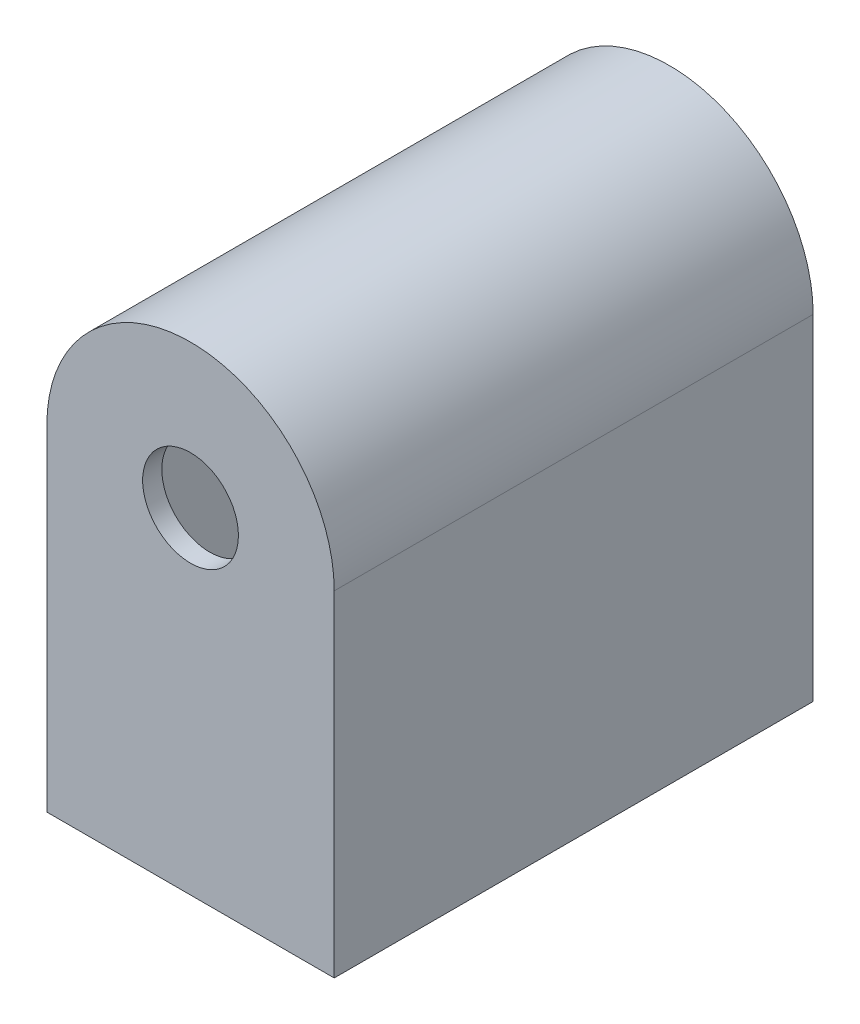
from build123d import *

# Parameters (mm, degrees)
ESQUISSE1_R             = 5
BOSS_EXTRU_1_DEPTH      = 50
ENL_V_MAT_EXTRU_2_DEPTH = 48


with BuildPart() as part:
    # Esquisse1 → Boss.-Extru.1 (new body)
    with BuildSketch(Plane.XY):
        with BuildLine():
            Line((-15, -17.5), (15, -17.5))
            Line((15, -17.5), (15, 17.5))
            ThreePointArc((15, 17.5), (0, 32.5), (-15, 17.5))
            Line((-15, 17.5), (-15, -17.5))
        make_face()
        with Locations((0, 17.5)):
            Circle(ESQUISSE1_R, mode=Mode.SUBTRACT)
    extrude(amount=-BOSS_EXTRU_1_DEPTH)

    # Esquisse2 → Enlèv. mat.-Extru.2 (cut)
    with BuildSketch(Plane(origin=(0, 0, -50), x_dir=(-1, 0, 0), z_dir=(0, 0, -1))):
        with BuildLine():
            Line((-13, 17.5), (-13, -15.5))
            Line((-13, -15.5), (13, -15.5))
            Line((13, -15.5), (13, 17.5))
            ThreePointArc((13, 17.5), (0, 30.5), (-13, 17.5))
        make_face()
    extrude(amount=-ENL_V_MAT_EXTRU_2_DEPTH, mode=Mode.SUBTRACT)


solid = part.part
